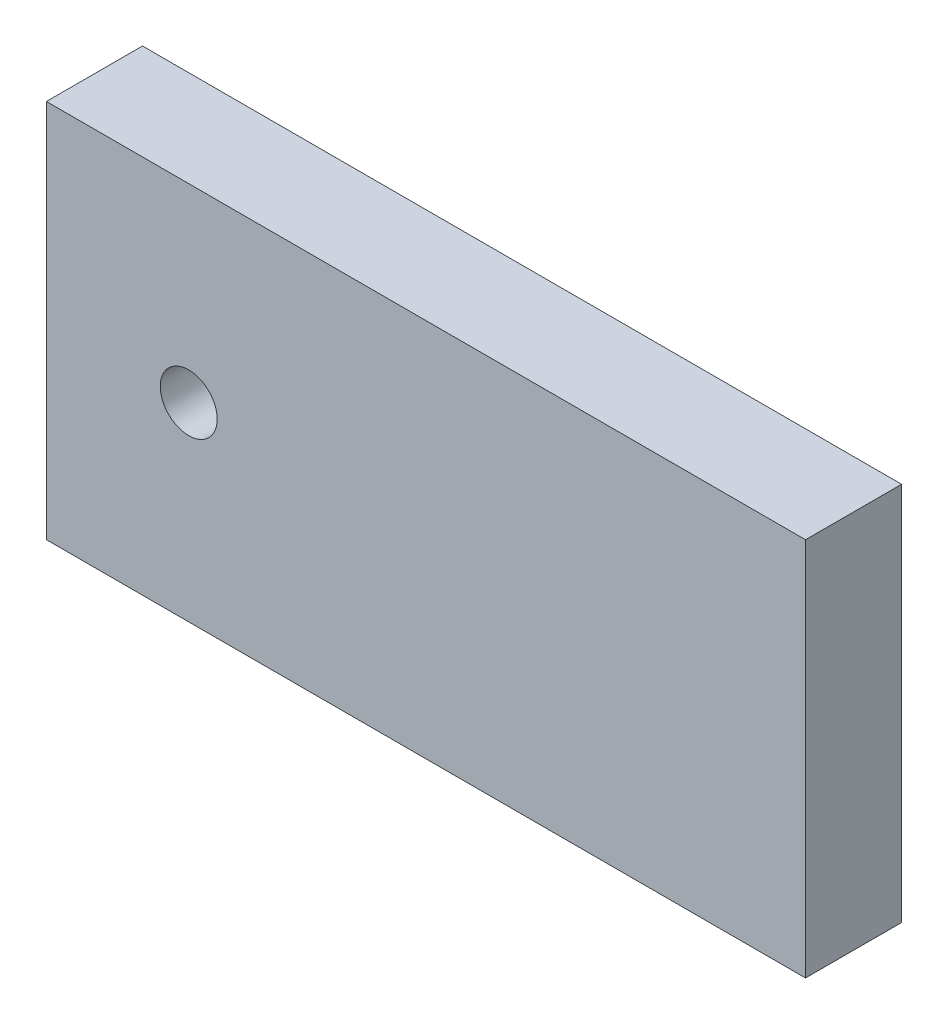
from build123d import *

# Parameters (mm, degrees)
ESQUISSE1_W             = 80
ESQUISSE1_H             = 40
BOSS_EXTRU_2_DEPTH      = 10.125
ESQUISSE3_R             = 3
ENL_V_MAT_EXTRU_1_DEPTH = 10.125


with BuildPart() as part:
    # Esquisse1 → Boss.-Extru.2 (new body)
    with BuildSketch(Plane.XY):
        with Locations((40, 20)):
            Rectangle(ESQUISSE1_W, ESQUISSE1_H)
    extrude(amount=BOSS_EXTRU_2_DEPTH)

    # Esquisse3 → Enlèv. mat.-Extru.1 (cut)
    with BuildSketch(Plane.XY.offset(10.125)):
        with Locations((15, 20)):
            Circle(ESQUISSE3_R)
    extrude(amount=-ENL_V_MAT_EXTRU_1_DEPTH, mode=Mode.SUBTRACT)


solid = part.part
